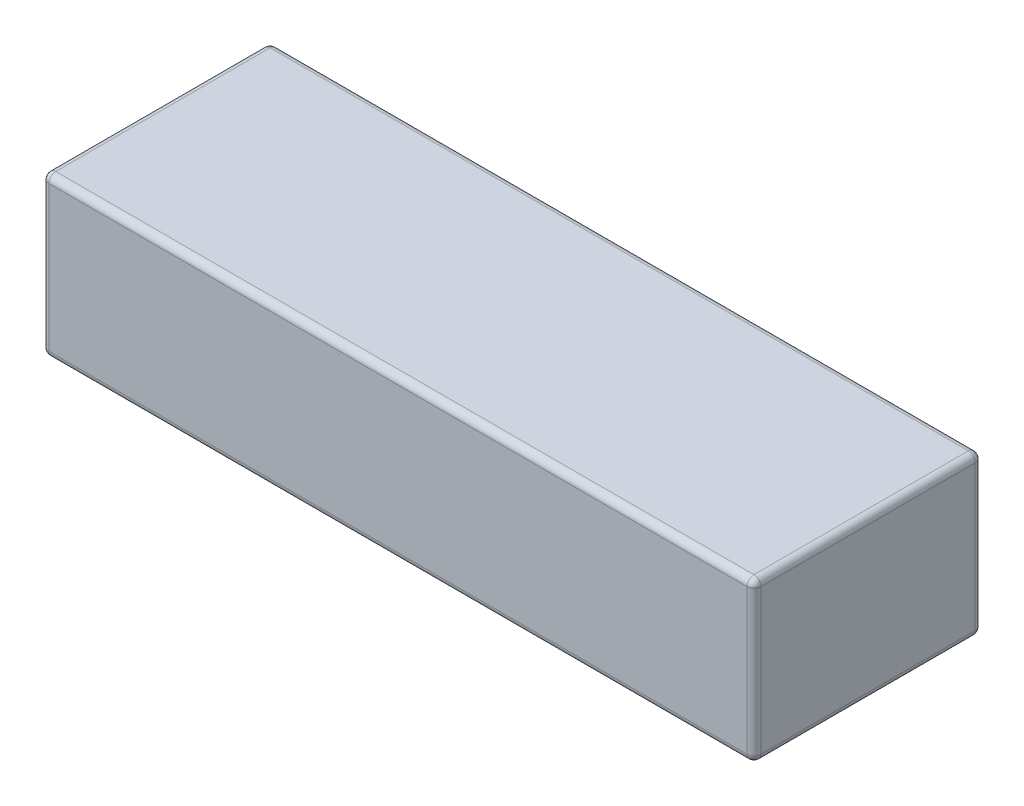
from build123d import *

# Parameters (mm, degrees)
SKETCH1_W           = 33
SKETCH1_H           = 23
BOSS_EXTRUDE1_DEPTH = 103
FILLET1_R           = 1


with BuildPart() as part:
    # Sketch1 → Boss-Extrude1 (new body)
    with BuildSketch(Plane(origin=(0, 0, 0), x_dir=(0, 0, -1), z_dir=(1, 0, 0))):
        with Locations((16.5, 11.5)):
            Rectangle(SKETCH1_W, SKETCH1_H)
    extrude(amount=BOSS_EXTRUDE1_DEPTH)

    # Fillet1
    fillet1_edges = [part.edges().sort_by_distance(p)[0] for p in [
        (103, 11.5, -33),
        (103, 23, -16.5),
        (103, 11.5, 0),
        (0, 23, -16.5),
        (0, 11.5, -33),
        (0, 0, -16.5),
        (0, 11.5, 0),
        (103, 0, -16.5),
        (51.5, 23, 0),
        (51.5, 23, -33),
        (51.5, 0, -33),
        (51.5, 0, 0),
    ]]
    fillet(fillet1_edges, radius=FILLET1_R)


solid = part.part
